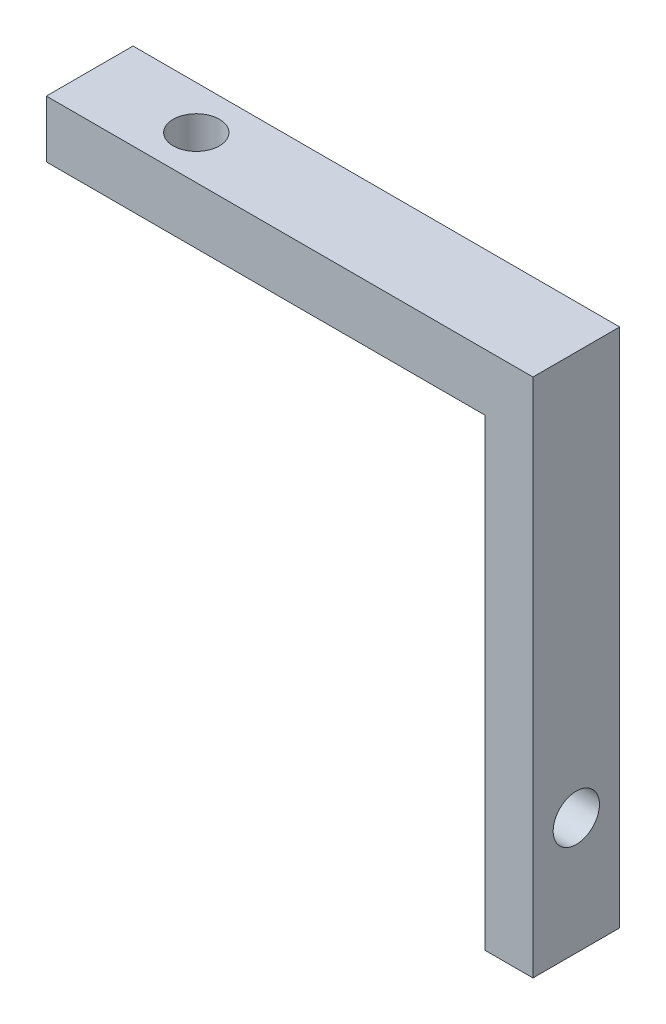
from build123d import *

# Parameters (mm, degrees)
BOSS_EXTRUDE1_DEPTH      = 3
BOSS_EXTRUDE1_DEPTH_BACK = 3
M3_CLEARANCE_HOLE1_D     = 3.2
M3_CLEARANCE_HOLE1_DEPTH = 3.947545897
M3_CLEARANCE_HOLE2_D     = 3.2
M3_CLEARANCE_HOLE2_DEPTH = 3.330741851


with BuildPart() as part:
    # Sketch1 → Boss-Extrude1 (new body, two sides)
    with BuildSketch(Plane.XY) as boss_extrude1_sk:
        Polygon((-7.378385455, 23.969381317), (22.968373629, 23.969381317), (22.968373629, -8.104429097), (26.29911548, -8.104429097), (26.29911548, 27.916927214), (-7.378385455, 27.916927214), align=None)
    extrude(amount=BOSS_EXTRUDE1_DEPTH)
    extrude(boss_extrude1_sk.sketch, amount=-BOSS_EXTRUDE1_DEPTH_BACK)

    # M3 Clearance Hole1
    with Locations(Plane(origin=(0, 27.916927214, 0), x_dir=(1, 0, 0), z_dir=(0, 1, 0))):
        with Locations((0, 0)):
            Hole(M3_CLEARANCE_HOLE1_D / 2, depth=M3_CLEARANCE_HOLE1_DEPTH)

    # M3 Clearance Hole2
    with Locations(Plane(origin=(26.29911548, 0, 0), x_dir=(0, 0, -1), z_dir=(1, 0, 0))):
        with Locations((0, 0)):
            Hole(M3_CLEARANCE_HOLE2_D / 2, depth=M3_CLEARANCE_HOLE2_DEPTH)


solid = part.part
